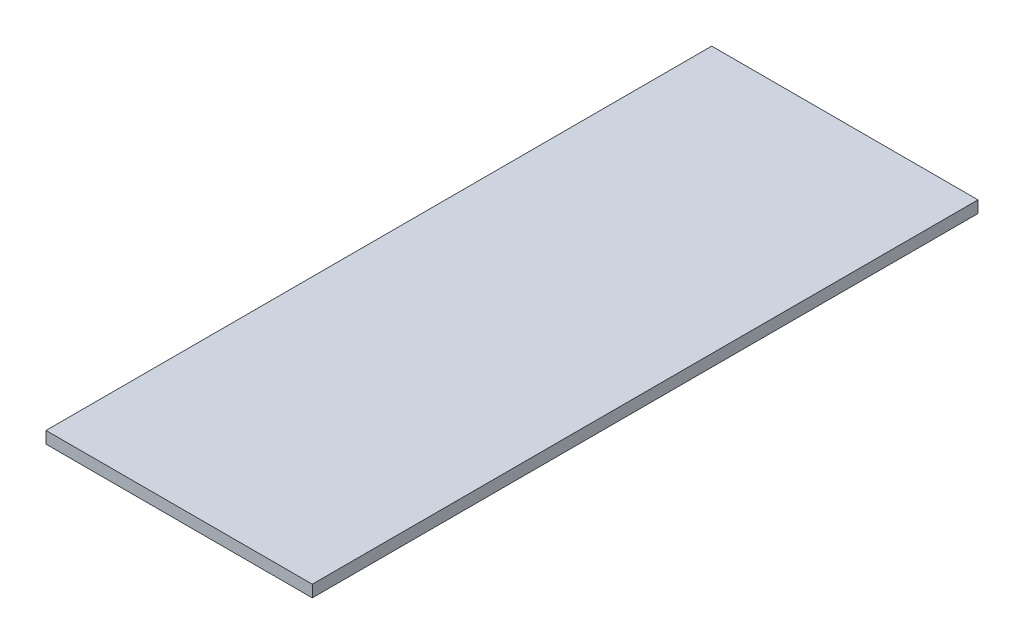
from build123d import *

# Parameters (mm, degrees)
SKETCH1_W           = 71.12
SKETCH1_H           = 177.8
BOSS_EXTRUDE1_DEPTH = 3.175


with BuildPart() as part:
    # Sketch1 → Boss-Extrude1 (new body)
    with BuildSketch(Plane(origin=(0, 0, 0), x_dir=(1, 0, 0), z_dir=(0, 1, 0))):
        with Locations((35.56, 88.9)):
            Rectangle(SKETCH1_W, SKETCH1_H)
    extrude(amount=BOSS_EXTRUDE1_DEPTH)


solid = part.part
